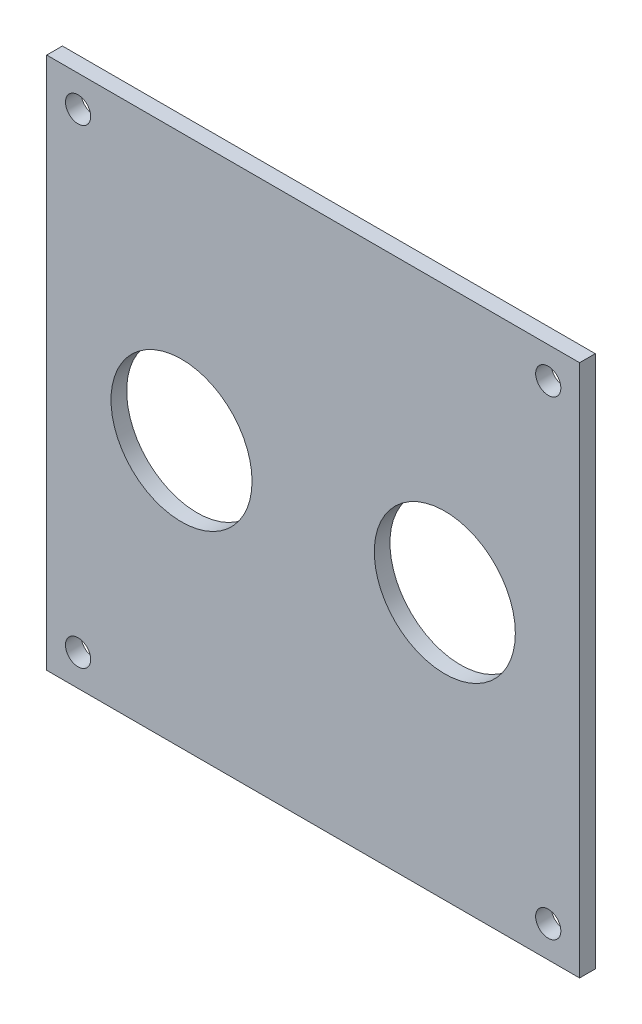
from build123d import *

# Parameters (mm, degrees)
SKETCH1_W           = 107.95
SKETCH1_H           = 107.95
BOSS_EXTRUDE1_DEPTH = 3.175
SKETCH2_R           = 2.5527
CUT_EXTRUDE1_DEPTH  = 3.175
SKETCH3_R           = 14.2875
CUT_EXTRUDE2_DEPTH  = 3.175


with BuildPart() as part:
    # Sketch1 → Boss-Extrude1 (new body)
    with BuildSketch(Plane.XY):
        with Locations((53.975, 53.975)):
            Rectangle(SKETCH1_W, SKETCH1_H)
    extrude(amount=BOSS_EXTRUDE1_DEPTH)

    # Sketch2 → Cut-Extrude1 (cut)
    with BuildSketch(Plane(origin=(0, 0, 0), x_dir=(-1, 0, 0), z_dir=(0, 0, -1))):
        with Locations((-6.35, 101.6)):
            Circle(SKETCH2_R)
        with Locations((-101.6, 101.6)):
            Circle(SKETCH2_R)
        with Locations((-101.6, 6.35)):
            Circle(SKETCH2_R)
        with Locations((-6.35, 6.35)):
            Circle(SKETCH2_R)
    extrude(amount=-CUT_EXTRUDE1_DEPTH, mode=Mode.SUBTRACT)

    # Sketch3 → Cut-Extrude2 (cut)
    with BuildSketch(Plane.XY.offset(3.175)):
        with Locations((27.305, 53.975)):
            Circle(SKETCH3_R)
        with Locations((80.645, 53.975)):
            Circle(SKETCH3_R)
    extrude(amount=-CUT_EXTRUDE2_DEPTH, mode=Mode.SUBTRACT)


solid = part.part
